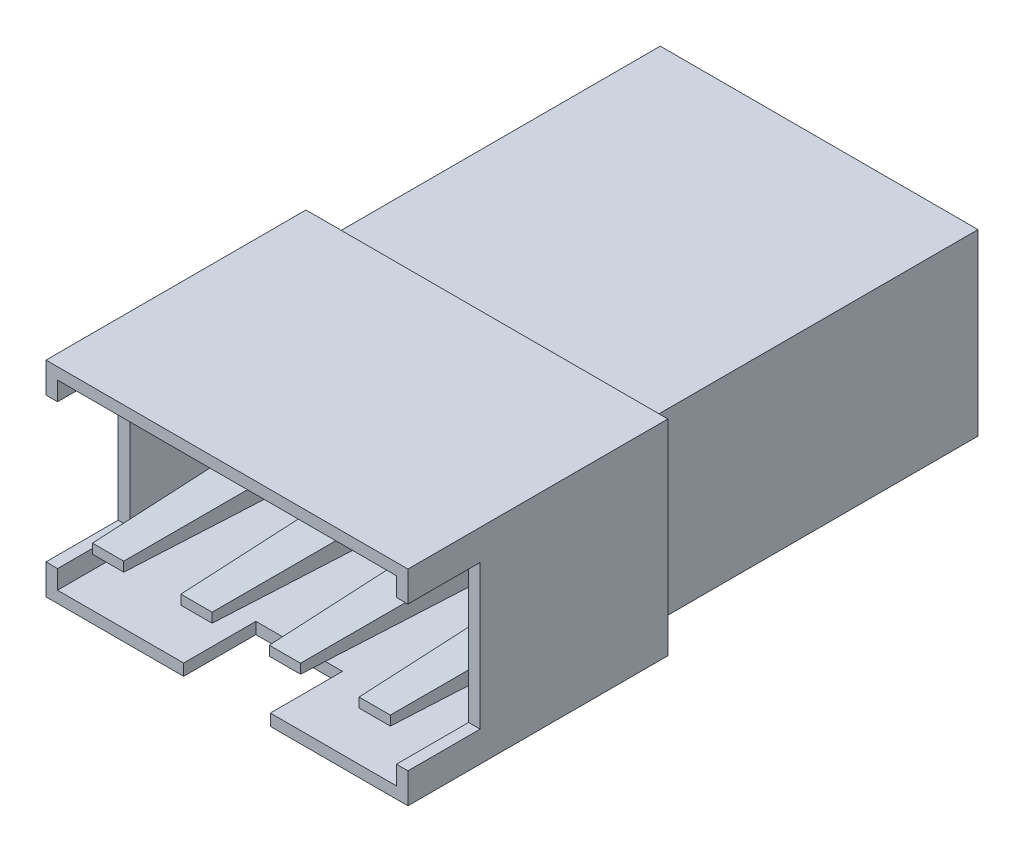
from build123d import *

# Parameters (mm, degrees)
SKETCH1_W           = 12.53
SKETCH1_H           = 7.1
BOSS_EXTRUDE1_DEPTH = 9
SKETCH2_W           = 11.73
SKETCH2_H           = 6.3
CUT_EXTRUDE1_DEPTH  = 8.5
SKETCH4_W           = 0.4
SKETCH4_H           = 5
SKETCH4_W_2         = 0.402982855
SKETCH4_W_3         = 3
SKETCH4_H_2         = 0.4
CUT_EXTRUDE3_DEPTH  = 2.5
SKETCH5_W           = 1.5
SKETCH5_H           = 0.750222952
BOSS_EXTRUDE4_DEPTH = 8
BOSS_EXTRUDE4_TAPER = 1.5
SKETCH8_W           = 11
SKETCH8_H           = 6.192617785
BOSS_EXTRUDE5_DEPTH = 11.5


with BuildPart() as part:
    # Sketch1 → Boss-Extrude1 (new body)
    with BuildSketch(Plane.XY):
        with Locations((6.265, -3.55)):
            Rectangle(SKETCH1_W, SKETCH1_H)
    extrude(amount=-BOSS_EXTRUDE1_DEPTH)

    # Sketch2 → Cut-Extrude1 (cut)
    with BuildSketch(Plane.XY):
        with Locations((6.265, -3.55)):
            Rectangle(SKETCH2_W, SKETCH2_H)
    extrude(amount=-CUT_EXTRUDE1_DEPTH, mode=Mode.SUBTRACT)

    # Sketch4 → Cut-Extrude3 (cut)
    with BuildSketch(Plane.XY):
        with Locations((0.2, -3.55)):
            Rectangle(SKETCH4_W, SKETCH4_H)
        with Locations((12.328508573, -3.55)):
            Rectangle(SKETCH4_W_2, SKETCH4_H)
        with Locations((6.265, -6.9)):
            Rectangle(SKETCH4_W_3, SKETCH4_H_2)
    extrude(amount=-CUT_EXTRUDE3_DEPTH, mode=Mode.SUBTRACT)

    # Sketch5 → Boss-Extrude4 (add)
    with BuildSketch(Plane.XY.offset(-8.5)):
        with Locations((1.65, -5.348826407)):
            Rectangle(SKETCH5_W, SKETCH5_H)
        with Locations((4.71, -5.348826407)):
            Rectangle(SKETCH5_W, SKETCH5_H)
        with Locations((7.77, -5.348826407)):
            Rectangle(SKETCH5_W, SKETCH5_H)
        with Locations((10.88, -5.348826407)):
            Rectangle(SKETCH5_W, SKETCH5_H)
    extrude(amount=BOSS_EXTRUDE4_DEPTH, taper=BOSS_EXTRUDE4_TAPER)

    # Sketch8 → Boss-Extrude5 (add)
    with BuildSketch(Plane(origin=(0, 0, -9), x_dir=(-1, 0, 0), z_dir=(0, 0, -1))):
        with Locations((-6.265, -3.552075665)):
            Rectangle(SKETCH8_W, SKETCH8_H)
    extrude(amount=BOSS_EXTRUDE5_DEPTH)


solid = part.part
